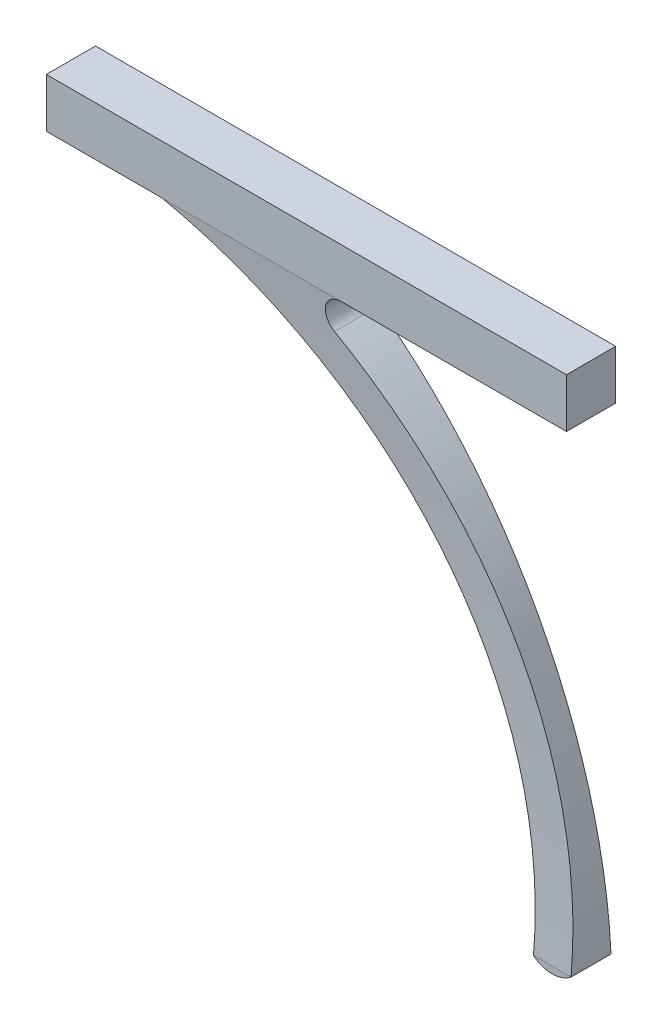
from build123d import *

# Parameters (mm, degrees)
BOSS_EXTRU_1_DEPTH           = 8.5
CONG_1_R                     = 3
ENL_V_MAT_EXTRU_1_DEPTH      = 75
ENL_V_MAT_EXTRU_1_DEPTH_BACK = 75


with BuildPart() as part:
    # Esquisse1 → Boss.-Extru.1 (new body)
    with BuildSketch(Plane.XY):
        with BuildLine():
            Line((-224.585731899, 132.259188945), (-314.419566448, 132.259188945))
            Line((-314.419566448, 132.259188945), (-314.419566448, 123.759188945))
            Line((-314.419566448, 123.759188945), (-294.419566448, 123.759188945))
            ThreePointArc((-294.419566448, 123.759188945), (-248.192676197, 93.980686318), (-231.088431446, 41.720477627))
            ThreePointArc((-231.088431446, 41.720477627), (-227.830567684, 40.59751219), (-224.585731899, 41.757584768))
            ThreePointArc((-224.585731899, 41.757584768), (-237.687220273, 90.187689192), (-274.970975671, 123.759188945))
            Line((-274.970975671, 123.759188945), (-224.585731899, 123.759188945))
            Line((-224.585731899, 123.759188945), (-224.585731899, 132.259188945))
        make_face()
    extrude(amount=BOSS_EXTRU_1_DEPTH)

    # Congé1
    cong_1_edges = [part.edges().sort_by_distance(p)[0] for p in [
        (-274.970975671, 123.759188945, 4.25),
    ]]
    fillet(cong_1_edges, radius=CONG_1_R)

    # Esquisse2 → Enlèv. mat.-Extru.1 (cut, two sides: drawn at the far end of the back side and taken through both)
    with BuildSketch(Plane(origin=(-224.585731899, 0, 0), x_dir=(0, 0, -1), z_dir=(1, 0, 0)).offset(-ENL_V_MAT_EXTRU_1_DEPTH_BACK)):
        with BuildLine():
            Line((-8.5, 81.05443386), (-8.5, 123.759188945))
            add(Edge.make_bspline(
                [(-7.696595714, 41.757584768), (-4.874996001, 82.844472097), (-8.5, 123.759188945)],
                knots=[0, 0, 0, 1, 1, 1], degree=2))
            Line((-7.696595714, 41.757584768), (-7.696595714, 34.641133104))
            Line((-7.696595714, 34.641133104), (-8.5, 34.641133104))
            Line((-8.5, 34.641133104), (-8.5, 81.05443386))
        make_face()
        with BuildLine():
            Line((0, 123.759188945), (0, 81.05443386))
            Line((0, 81.05443386), (0, 36.772624368))
            Line((0, 36.772624368), (-0.803404286, 36.772624368))
            Line((-0.803404286, 36.772624368), (-0.803404286, 41.757584768))
            add(Edge.make_bspline(
                [(-0.803404286, 41.757584768), (-3.625003999, 82.844472097), (0, 123.759188945)],
                knots=[0, 0, 0, 1, 1, 1], degree=2))
        make_face()
    extrude(amount=ENL_V_MAT_EXTRU_1_DEPTH + ENL_V_MAT_EXTRU_1_DEPTH_BACK, mode=Mode.SUBTRACT)


solid = part.part
